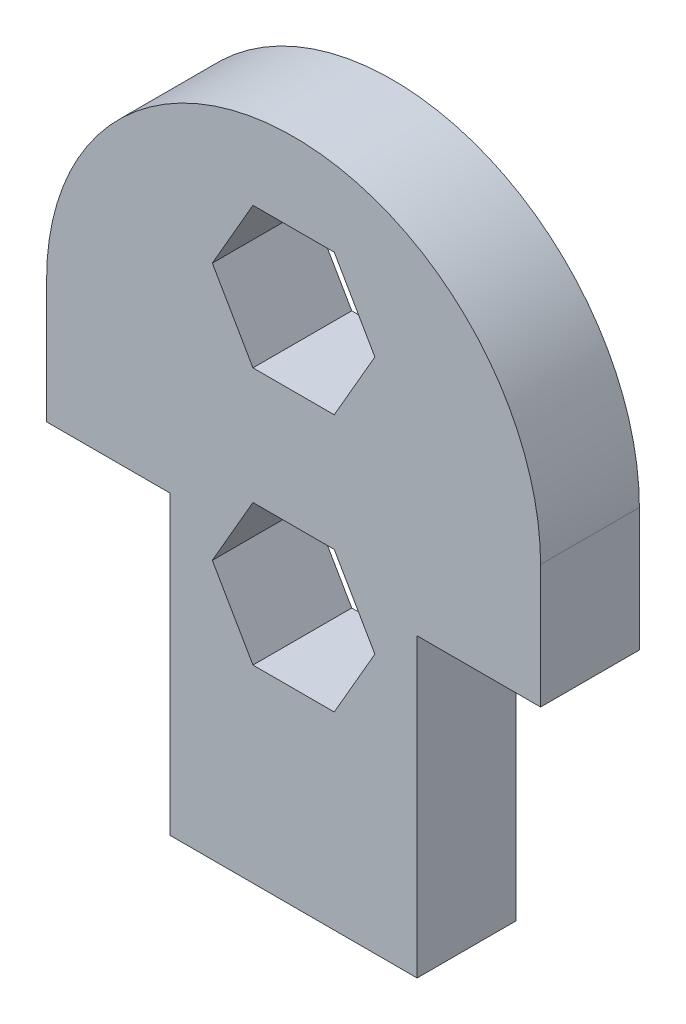
from build123d import *

# Parameters (mm, degrees)
BOSS_EXTRUDE1_DEPTH = 4
SKETCH2_W           = 2.5
SKETCH2_H           = 4
CUT_EXTRUDE1_DEPTH  = 4


with BuildPart() as part:
    # Sketch1 → Boss-Extrude1 (new body)
    with BuildSketch(Plane.XY):
        with BuildLine():
            Line((0, 0), (10, 0))
            Line((10, 0), (10, 4))
            Line((10, 4), (12.5, 4))
            Line((12.5, 4), (12.5, 8))
            Line((12.5, 8), (10, 8))
            Line((10, 8), (10, 12))
            Line((10, 12), (15, 12))
            Line((15, 12), (15, 17))
            ThreePointArc((15, 17), (5, 27), (-5, 17))
            Line((-5, 17), (-5, 12))
            Line((-5, 12), (0, 12))
            Line((0, 12), (0, 8))
            Line((0, 8), (-2.5, 8))
            Line((-2.5, 8), (-2.5, 4))
            Line((-2.5, 4), (0, 4))
            Line((0, 4), (0, 0))
        make_face()
        Polygon((3.354551733, 18.071172359), (6.645448267, 18.071172359), (8.290896534, 20.921172359), (6.645448267, 23.771172359), (3.354551733, 23.771172359), (1.709103466, 20.921172359), align=None, mode=Mode.SUBTRACT)
        Polygon((8.290896534, 10.5), (6.645448267, 13.35), (3.354551733, 13.35), (1.709103466, 10.5), (3.354551733, 7.65), (6.645448267, 7.65), align=None, mode=Mode.SUBTRACT)
    extrude(amount=BOSS_EXTRUDE1_DEPTH)

    # Sketch2 → Cut-Extrude1 (cut)
    with BuildSketch(Plane.XY.offset(4)):
        with Locations((-1.25, 6)):
            Rectangle(SKETCH2_W, SKETCH2_H)
        with Locations((11.25, 6)):
            Rectangle(SKETCH2_W, SKETCH2_H)
    extrude(amount=-CUT_EXTRUDE1_DEPTH, mode=Mode.SUBTRACT)


solid = part.part
